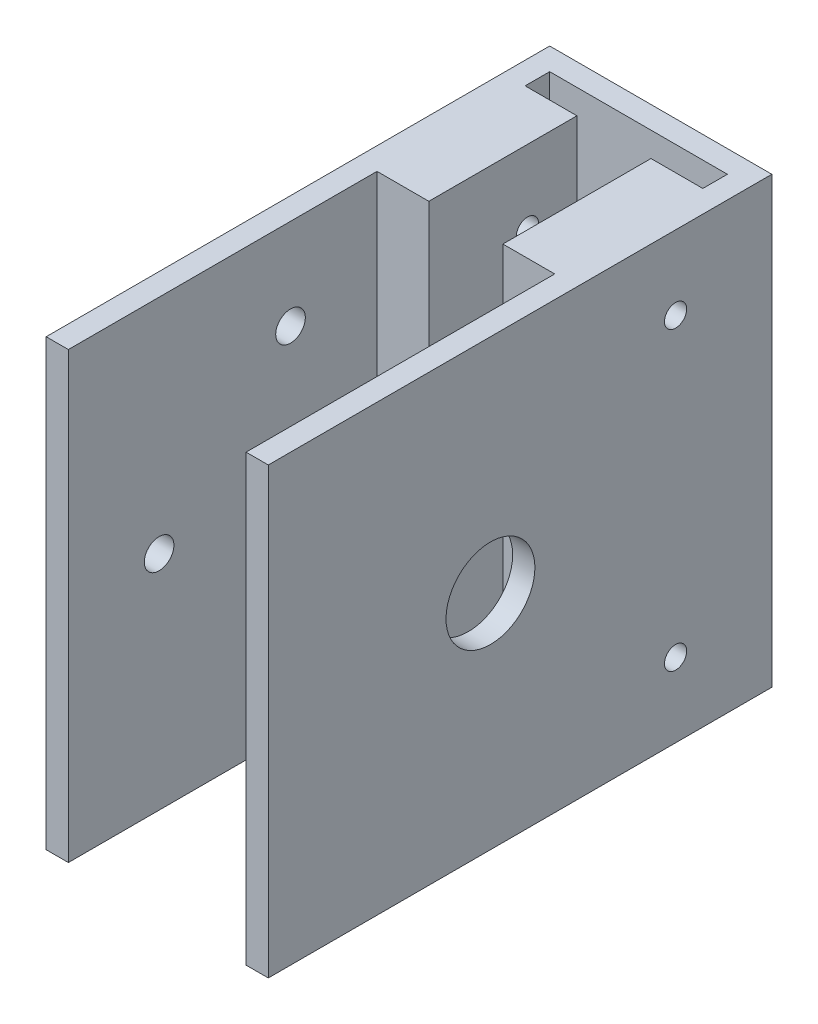
from build123d import *

# Parameters (mm, degrees)
SKETCH1_W               = 30
SKETCH1_H               = 60
SKETCH1_R               = 2.9
BOSS_EXTRUDE1_DEPTH     = 3
SKETCH2_W               = 3
SKETCH2_H               = 60
BOSS_EXTRUDE2_DEPTH     = 65
SKETCH5_W               = 7
SKETCH5_H               = 20
BOSS_EXTRUDE3_DEPTH     = 60
CUT_EXTRUDE1_REACH      = 32
SKETCH3_R               = 1.5
SKETCH3_R_2             = 6
SKETCH3_R_3             = 2
SKETCH4_R               = 1.5
SKETCH4_R_2             = 6
CUT_EXTRUDE2_DEPTH      = 28
CUT_EXTRUDE2_DEPTH_BACK = 4


with BuildPart() as part:
    # Sketch1 → Boss-Extrude1 (new body)
    with BuildSketch(Plane.XY):
        Rectangle(SKETCH1_W, SKETCH1_H)
        with Locations((0, 15)):
            Circle(SKETCH1_R, mode=Mode.SUBTRACT)
        with Locations((0, -15)):
            Circle(SKETCH1_R, mode=Mode.SUBTRACT)
    extrude(amount=BOSS_EXTRUDE1_DEPTH)

    # Sketch2 → Boss-Extrude2 (add)
    with BuildSketch(Plane.XY.offset(3)):
        with Locations((-13.5, 0)):
            Rectangle(SKETCH2_W, SKETCH2_H)
        with Locations((13.5, 0)):
            Rectangle(SKETCH2_W, SKETCH2_H)
    extrude(amount=BOSS_EXTRUDE2_DEPTH)

    # Sketch5 → Boss-Extrude3 (add)
    with BuildSketch(Plane(origin=(0, 30, 0), x_dir=(1, 0, 0), z_dir=(0, 1, 0))):
        with Locations((8.5, -16.320138996)):
            Rectangle(SKETCH5_W, SKETCH5_H)
        with Locations((-8.5, -16.320138996)):
            Rectangle(SKETCH5_W, SKETCH5_H)
    extrude(amount=-BOSS_EXTRUDE3_DEPTH)

    # Sketch3 → Cut-Extrude1 (cut, up to next)
    with BuildSketch(Plane.ZY.offset(15), mode=Mode.PRIVATE) as cut_extrude1_sk1:
        with Locations((13, 20)):
            Circle(SKETCH3_R)
    cut_extrude1_tool1 = extrude(cut_extrude1_sk1.sketch, amount=-CUT_EXTRUDE1_REACH, mode=Mode.PRIVATE) & part.part
    add(cut_extrude1_tool1.solids().sort_by_distance((-15, 20, 13))[0], mode=Mode.SUBTRACT)
    # Sketch3 → Cut-Extrude1 (cut, up to next)
    with BuildSketch(Plane.ZY.offset(15), mode=Mode.PRIVATE) as cut_extrude1_sk2:
        with Locations((38, 0)):
            Circle(SKETCH3_R_2)
    cut_extrude1_tool2 = extrude(cut_extrude1_sk2.sketch, amount=-CUT_EXTRUDE1_REACH, mode=Mode.PRIVATE) & part.part
    add(cut_extrude1_tool2.solids().sort_by_distance((-15, 0, 38))[0], mode=Mode.SUBTRACT)
    # Sketch3 → Cut-Extrude1 (cut, up to next)
    with BuildSketch(Plane.ZY.offset(15), mode=Mode.PRIVATE) as cut_extrude1_sk3:
        with Locations((20.25, 0)):
            Circle(SKETCH3_R_3)
    cut_extrude1_tool3 = extrude(cut_extrude1_sk3.sketch, amount=-CUT_EXTRUDE1_REACH, mode=Mode.PRIVATE) & part.part
    add(cut_extrude1_tool3.solids().sort_by_distance((-15, 0, 20.25))[0], mode=Mode.SUBTRACT)
    # Sketch3 → Cut-Extrude1 (cut, up to next)
    with BuildSketch(Plane.ZY.offset(15), mode=Mode.PRIVATE) as cut_extrude1_sk4:
        with Locations((38, 17.75)):
            Circle(SKETCH3_R_3)
    cut_extrude1_tool4 = extrude(cut_extrude1_sk4.sketch, amount=-CUT_EXTRUDE1_REACH, mode=Mode.PRIVATE) & part.part
    add(cut_extrude1_tool4.solids().sort_by_distance((-15, 17.75, 38))[0], mode=Mode.SUBTRACT)
    # Sketch3 → Cut-Extrude1 (cut, up to next)
    with BuildSketch(Plane.ZY.offset(15), mode=Mode.PRIVATE) as cut_extrude1_sk5:
        with Locations((55.75, 0)):
            Circle(SKETCH3_R_3)
    cut_extrude1_tool5 = extrude(cut_extrude1_sk5.sketch, amount=-CUT_EXTRUDE1_REACH, mode=Mode.PRIVATE) & part.part
    add(cut_extrude1_tool5.solids().sort_by_distance((-15, 0, 55.75))[0], mode=Mode.SUBTRACT)
    # Sketch3 → Cut-Extrude1 (cut, up to next)
    with BuildSketch(Plane.ZY.offset(15), mode=Mode.PRIVATE) as cut_extrude1_sk6:
        with Locations((38, -17.75)):
            Circle(SKETCH3_R_3)
    cut_extrude1_tool6 = extrude(cut_extrude1_sk6.sketch, amount=-CUT_EXTRUDE1_REACH, mode=Mode.PRIVATE) & part.part
    add(cut_extrude1_tool6.solids().sort_by_distance((-15, -17.75, 38))[0], mode=Mode.SUBTRACT)
    # Sketch3 → Cut-Extrude1 (cut, up to next)
    with BuildSketch(Plane.ZY.offset(15), mode=Mode.PRIVATE) as cut_extrude1_sk7:
        with Locations((13, -20)):
            Circle(SKETCH3_R)
    cut_extrude1_tool7 = extrude(cut_extrude1_sk7.sketch, amount=-CUT_EXTRUDE1_REACH, mode=Mode.PRIVATE) & part.part
    add(cut_extrude1_tool7.solids().sort_by_distance((-15, -20, 13))[0], mode=Mode.SUBTRACT)

    # Sketch4 → Cut-Extrude2 (cut, two sides)
    with BuildSketch(Plane.ZY.offset(-12)) as cut_extrude2_sk:
        with Locations((13, -20)):
            Circle(SKETCH4_R)
        with Locations((13, 20)):
            Circle(SKETCH4_R)
        with Locations((38, 0)):
            Circle(SKETCH4_R_2)
    extrude(amount=CUT_EXTRUDE2_DEPTH, mode=Mode.SUBTRACT)
    extrude(cut_extrude2_sk.sketch, amount=-CUT_EXTRUDE2_DEPTH_BACK, mode=Mode.SUBTRACT)


solid = part.part
